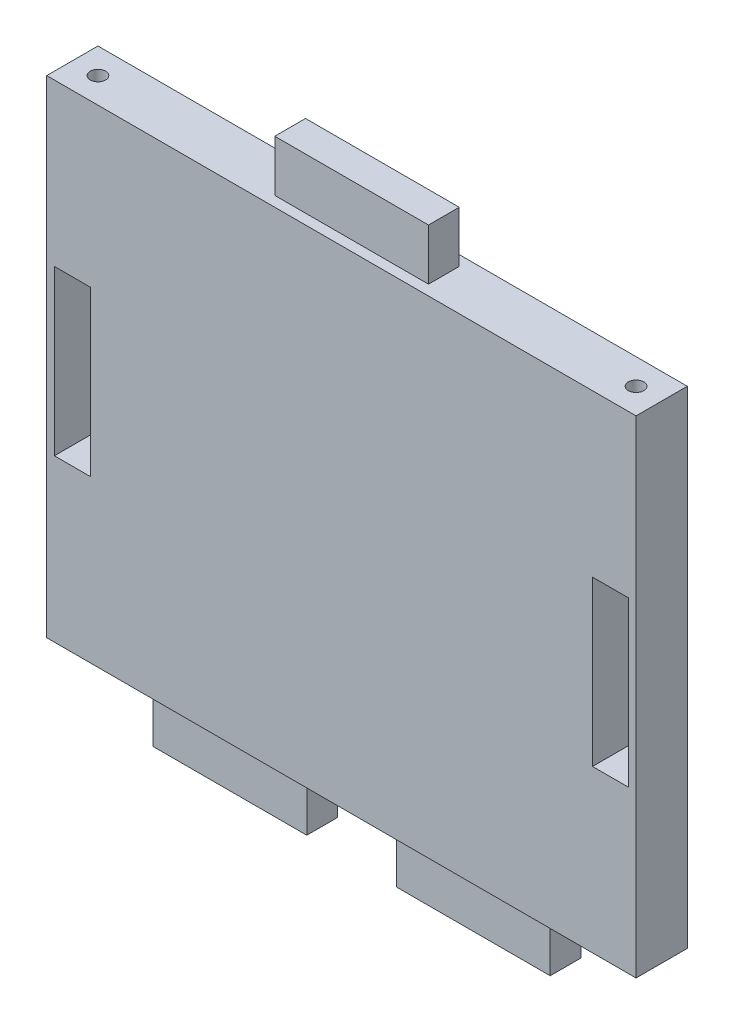
from build123d import *

# Parameters (mm, degrees)
ESBO_O1_W                = 115
ESBO_O1_H                = 95
RESSALTO_EXTRUS_O1_DEPTH = 10
ESBO_O2_W                = 30
ESBO_O2_H                = 6
RESSALTO_EXTRUS_O2_DEPTH = 10
ESBO_O3_W                = 30
ESBO_O3_H                = 6
RESSALTO_EXTRUS_O3_DEPTH = 10
ESBO_O4_W                = 7
ESBO_O4_H                = 32
CORTE_EXTRUS_O1_DEPTH    = 11
ESBO_O5_R                = 1.5
CORTE_EXTRUS_O2_DEPTH    = 8
ESBO_O6_R                = 1.5
CORTE_EXTRUS_O3_DEPTH    = 8


with BuildPart() as part:
    # Esboço1 → Ressalto-extrusão1 (new body)
    with BuildSketch(Plane.XY):
        Rectangle(ESBO_O1_W, ESBO_O1_H)
    extrude(amount=RESSALTO_EXTRUS_O1_DEPTH)

    # Esboço2 → Ressalto-extrusão2 (add)
    with BuildSketch(Plane(origin=(0, 47.5, 0), x_dir=(1, 0, 0), z_dir=(0, 1, 0))):
        with Locations((0, -5)):
            Rectangle(ESBO_O2_W, ESBO_O2_H)
    extrude(amount=RESSALTO_EXTRUS_O2_DEPTH)

    # Esboço3 → Ressalto-extrusão3 (add)
    with BuildSketch(Plane.XZ.offset(47.5)):
        with Locations((23.75, 5)):
            Rectangle(ESBO_O3_W, ESBO_O3_H)
        with Locations((-23.75, 5)):
            Rectangle(ESBO_O3_W, ESBO_O3_H)
    extrude(amount=RESSALTO_EXTRUS_O3_DEPTH)

    # Esboço4 → Corte-extrusão1 (cut, through all)
    with BuildSketch(Plane.XY.offset(10)):
        with Locations((-52.5, 0)):
            Rectangle(ESBO_O4_W, ESBO_O4_H)
        with Locations((52.5, 0)):
            Rectangle(ESBO_O4_W, ESBO_O4_H)
    extrude(amount=-CORTE_EXTRUS_O1_DEPTH, mode=Mode.SUBTRACT)

    # Esboço5 → Corte-extrusão2 (cut)
    with BuildSketch(Plane(origin=(0, 47.5, 0), x_dir=(1, 0, 0), z_dir=(0, 1, 0))):
        with Locations((52.5, -5)):
            Circle(ESBO_O5_R)
        with Locations((-52.5, -5)):
            Circle(ESBO_O5_R)
    extrude(amount=-CORTE_EXTRUS_O2_DEPTH, mode=Mode.SUBTRACT)

    # Esboço6 → Corte-extrusão3 (cut)
    with BuildSketch(Plane.XZ.offset(47.5)):
        with Locations((-52.5, 5)):
            Circle(ESBO_O6_R)
        with Locations((52.5, 5)):
            Circle(ESBO_O6_R)
    extrude(amount=-CORTE_EXTRUS_O3_DEPTH, mode=Mode.SUBTRACT)


solid = part.part
